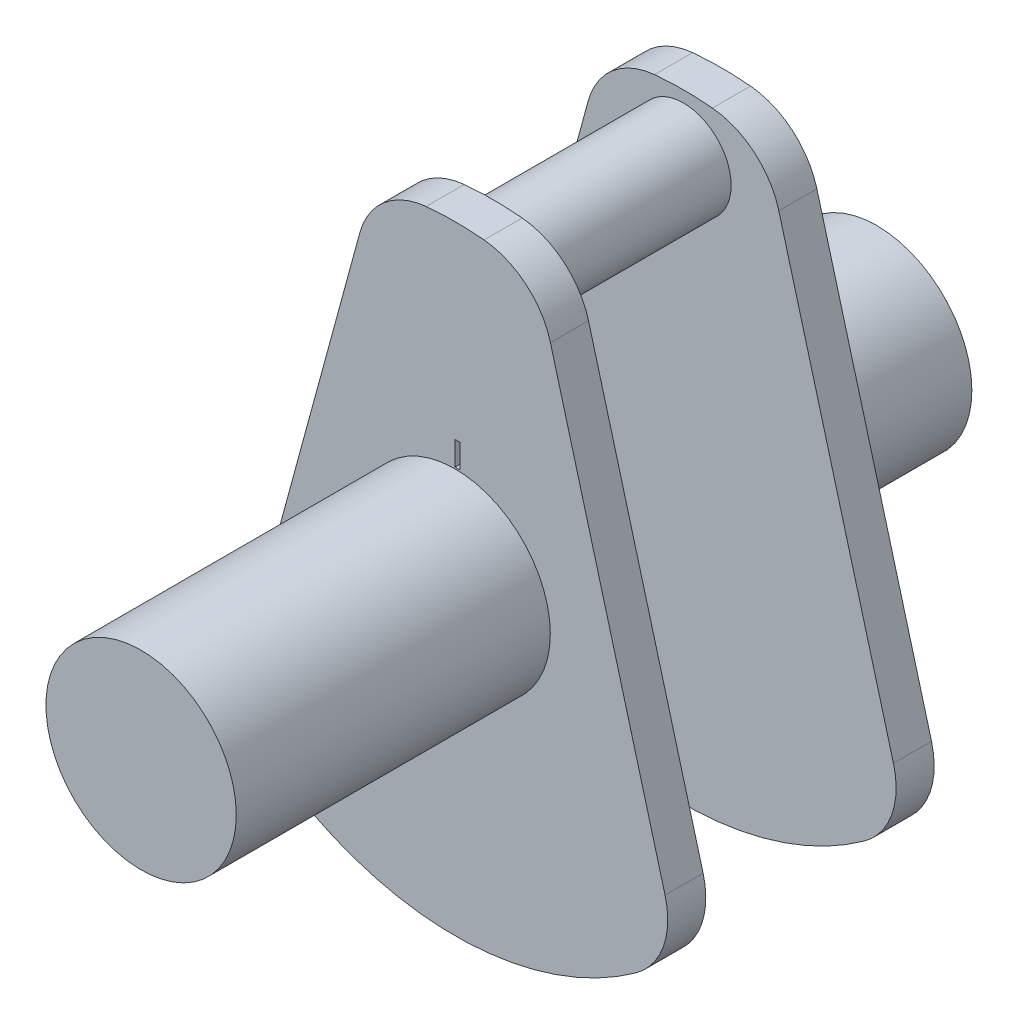
from build123d import *

# Parameters (mm, degrees)
BOSS_EXTRUDE1_DEPTH = 0.8
SKETCH2_R           = 1
BOSS_EXTRUDE2_DEPTH = 2
SKETCH3_R           = 2
BOSS_EXTRUDE3_DEPTH = 3.26
SKETCH4_R           = 2
BOSS_EXTRUDE4_DEPTH = 3.34
SKETCH6_W           = 0.1
SKETCH6_H           = 0.5
CUT_EXTRUDE2_DEPTH  = 0.1


with BuildPart() as part:
    # Sketch1 → Boss-Extrude1 (new body)
    with BuildSketch(Plane.XY):
        with BuildLine():
            Line((-2.002843202, 5.298630925), (-4.411867861, -3.552786589))
            ThreePointArc((-4.411867861, -3.552786589), (-4.376483825, -4.506396112), (-3.804522508, -5.270256966))
            ThreePointArc((-3.804522508, -5.270256966), (0, -6.5), (3.804522508, -5.270256966))
            ThreePointArc((3.804522508, -5.270256966), (4.376483825, -4.506396112), (4.411867861, -3.552786589))
            Line((4.411867861, -3.552786589), (2.002843202, 5.298630925))
            ThreePointArc((2.002843202, 5.298630925), (1.489063424, 6.102778606), (0.608877551, 6.471419329))
            ThreePointArc((0.608877551, 6.471419329), (0, 6.5), (-0.608877551, 6.471419329))
            ThreePointArc((-0.608877551, 6.471419329), (-1.489063424, 6.102778606), (-2.002843202, 5.298630925))
        make_face()
    extrude(amount=BOSS_EXTRUDE1_DEPTH)

    # Sketch2 → Boss-Extrude2 (add)
    with BuildSketch(Plane.XY.offset(0.8)):
        with Locations((0, 5.259)):
            Circle(SKETCH2_R)
    extrude(amount=BOSS_EXTRUDE2_DEPTH)

    # Sketch3 → Boss-Extrude3 (add)
    with BuildSketch(Plane(origin=(0, 0, 0), x_dir=(-1, 0, 0), z_dir=(0, 0, -1))):
        Circle(SKETCH3_R)
    extrude(amount=BOSS_EXTRUDE3_DEPTH)

    # Mirror3: part across plane


with BuildPart() as part_1:
    add(part.part)
    add(part.part.mirror(Plane(origin=(0, 5.259, 2.8), x_dir=(1, 0, 0), z_dir=(0, 0, 1))))

    # Sketch4 → Boss-Extrude4 (add)
    with BuildSketch(Plane.XY.offset(8.86)):
        Circle(SKETCH4_R)
    extrude(amount=BOSS_EXTRUDE4_DEPTH)

    # Sketch6 → Cut-Extrude2 (cut)
    with BuildSketch(Plane.XY.offset(5.6)):
        with Locations((0.05, 2.283256651)):
            Rectangle(SKETCH6_W, SKETCH6_H)
    extrude(amount=-CUT_EXTRUDE2_DEPTH, mode=Mode.SUBTRACT)


solid = part_1.part
